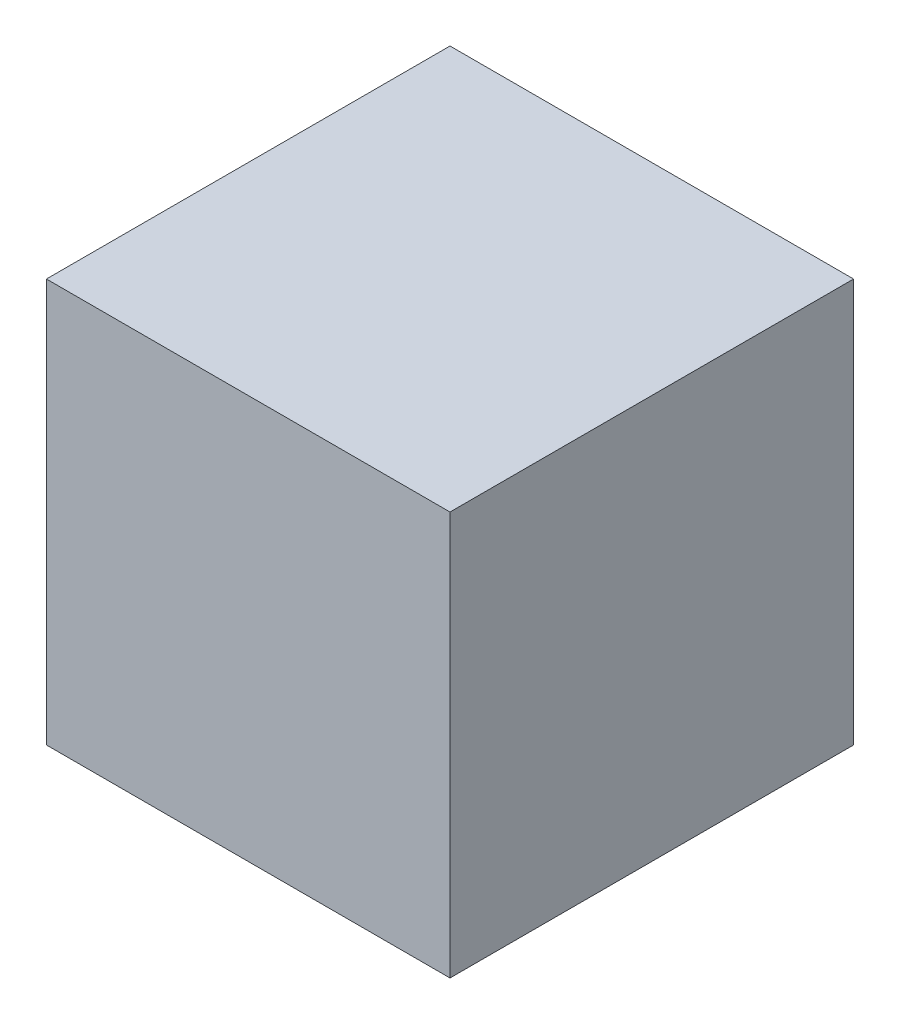
from build123d import *

# Parameters (mm, degrees)
SKETCH1_W           = 25.4
SKETCH1_H           = 25.4
BOSS_EXTRUDE1_DEPTH = 12.7


with BuildPart() as part:
    # Sketch1 → Boss-Extrude1 (new body, symmetric)
    with BuildSketch(Plane(origin=(0, 0, 0), x_dir=(1, 0, 0), z_dir=(0, 1, 0))):
        Rectangle(SKETCH1_W, SKETCH1_H)
    extrude(amount=BOSS_EXTRUDE1_DEPTH, both=True)


solid = part.part
